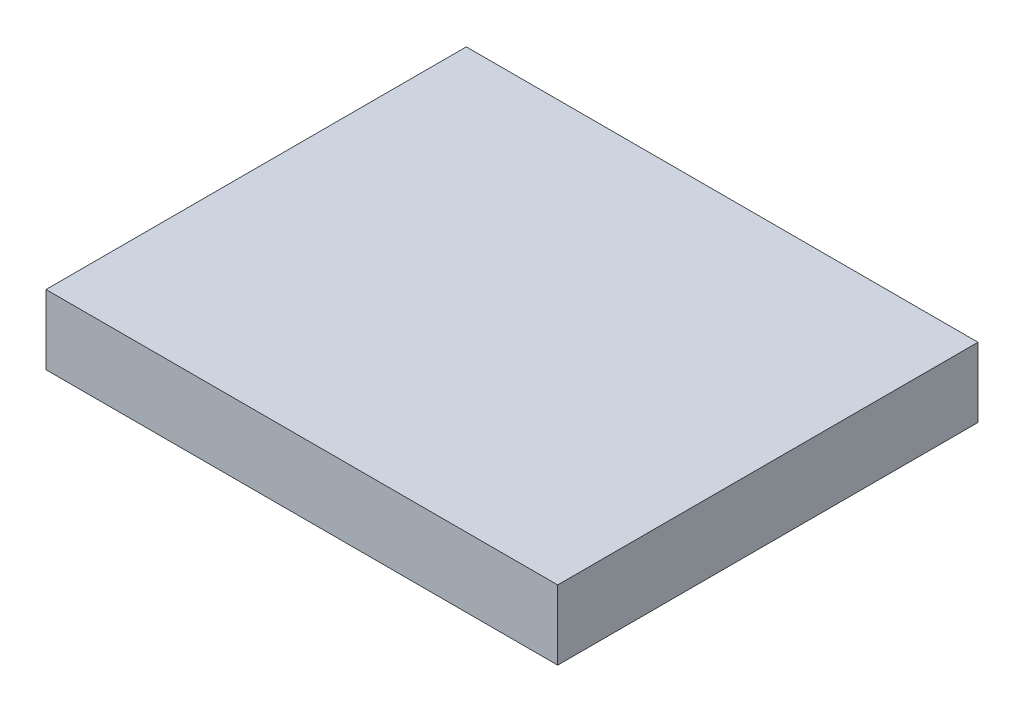
from build123d import *

# Parameters (mm, degrees)
SKETCH2_W           = 35.56
SKETCH2_H           = 29.21
BOSS_EXTRUDE1_DEPTH = 4.83


with BuildPart() as part:
    # Sketch2 → Boss-Extrude1 (new body)
    with BuildSketch(Plane(origin=(0, 0, 0), x_dir=(1, 0, 0), z_dir=(0, 1, 0))):
        with Locations((0.711753753, -17.630923652)):
            Rectangle(SKETCH2_W, SKETCH2_H)
    extrude(amount=BOSS_EXTRUDE1_DEPTH)


solid = part.part
